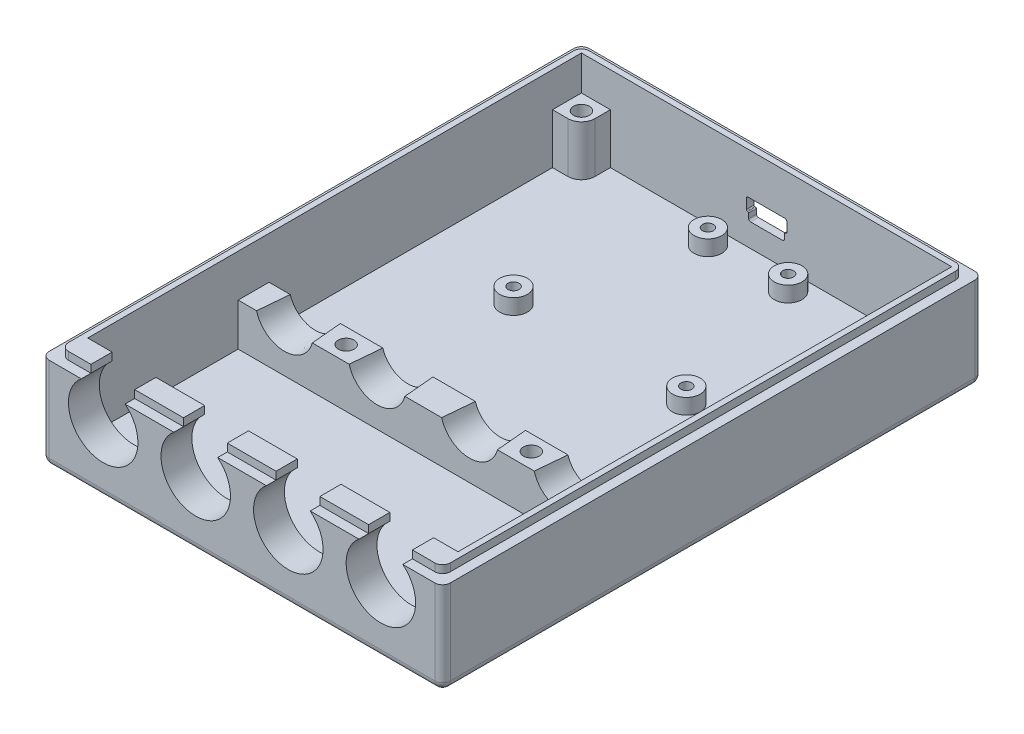
from build123d import *

# Parameters (mm, degrees)
SKETCH1_W                                       = 82.55
SKETCH1_H                                       = 111.125
BOSS_EXTRUDE1_DEPTH                             = 19.05
SKETCH14_W                                      = 76.2
SKETCH14_H                                      = 101.6
CUT_EXTRUDE3_DEPTH                              = 15.875
CUT_EXTRUDE4_REACH                              = 113.125
SKETCH11_R                                      = 7.1501
SKETCH17_W                                      = 76.2
SKETCH17_H                                      = 6.35
BOSS_EXTRUDE4_DEPTH                             = 10.3251
SKETCH18_R                                      = 5.953125
CUT_EXTRUDE5_DEPTH                              = 6.35
CUT_EXTRUDE5_TAPER                              = 5
CUT_EXTRUDE7_REACH                              = 113.125
FILLET6_R                                       = 1.5875
SKETCH19_R                                      = 2.8575
BOSS_EXTRUDE8_DEPTH                             = 3.175
CBORE_FOR_4_PAN_HEAD_MACHINE_SCREW3_D           = 3.2639
CBORE_FOR_4_PAN_HEAD_MACHINE_SCREW3_CBORE_D     = 6.35
CBORE_FOR_4_PAN_HEAD_MACHINE_SCREW3_CBORE_DEPTH = 2.032
F_4_40_TAPPED_HOLE1_D                           = 2.2606
F_4_40_TAPPED_HOLE1_DEPTH                       = 4.7752
F_4_40_TAPPED_HOLE1_TIP                         = 0.679152758
SKETCH39_W                                      = 17.4625
SKETCH39_H                                      = 14.2875
CUT_EXTRUDE8_DEPTH                              = 1.5875
FILLET7_R                                       = 0.79375
FILLET8_R                                       = 0.1984375
FILLET9_R                                       = 0.396875
SKETCH40_W                                      = 10.03389441
SKETCH40_H                                      = 4.365625
BOSS_EXTRUDE9_DEPTH                             = 1.5875
FILLET10_R                                      = 1.5875
SKETCH41_W                                      = 76.2
SKETCH41_H                                      = 6.35
CUT_EXTRUDE9_DEPTH                              = 1.5875


with BuildPart() as part:
    # Sketch1 → Boss-Extrude1 (new body)
    with BuildSketch(Plane(origin=(0, 0, 0), x_dir=(1, 0, 0), z_dir=(0, 1, 0))):
        Rectangle(SKETCH1_W, SKETCH1_H)
    extrude(amount=BOSS_EXTRUDE1_DEPTH)

    # Sketch14 → Cut-Extrude3 (cut)
    with BuildSketch(Plane(origin=(0, 19.05, 0), x_dir=(-1, 0, 0), z_dir=(0, 1, 0))):
        with Locations((0, -1.5875)):
            Rectangle(SKETCH14_W, SKETCH14_H)
    extrude(amount=-CUT_EXTRUDE3_DEPTH, mode=Mode.SUBTRACT)

    # Sketch11 → Cut-Extrude4 (cut, up to next)
    with BuildSketch(Plane.XY.offset(55.5625), mode=Mode.PRIVATE) as cut_extrude4_sk1:
        with Locations((-28.575, 13.5001)):
            Circle(SKETCH11_R)
    cut_extrude4_tool1 = extrude(cut_extrude4_sk1.sketch, amount=-CUT_EXTRUDE4_REACH, mode=Mode.PRIVATE) & part.part
    add(cut_extrude4_tool1.solids().sort_by_distance((-28.575, 13.5001, 55.5625))[0], mode=Mode.SUBTRACT)
    # Sketch11 → Cut-Extrude4 (cut, up to next)
    with BuildSketch(Plane.XY.offset(55.5625), mode=Mode.PRIVATE) as cut_extrude4_sk2:
        with Locations((-9.525, 13.5001)):
            Circle(SKETCH11_R)
    cut_extrude4_tool2 = extrude(cut_extrude4_sk2.sketch, amount=-CUT_EXTRUDE4_REACH, mode=Mode.PRIVATE) & part.part
    add(cut_extrude4_tool2.solids().sort_by_distance((-9.525, 13.5001, 55.5625))[0], mode=Mode.SUBTRACT)
    # Sketch11 → Cut-Extrude4 (cut, up to next)
    with BuildSketch(Plane.XY.offset(55.5625), mode=Mode.PRIVATE) as cut_extrude4_sk3:
        with Locations((9.525, 13.5001)):
            Circle(SKETCH11_R)
    cut_extrude4_tool3 = extrude(cut_extrude4_sk3.sketch, amount=-CUT_EXTRUDE4_REACH, mode=Mode.PRIVATE) & part.part
    add(cut_extrude4_tool3.solids().sort_by_distance((9.525, 13.5001, 55.5625))[0], mode=Mode.SUBTRACT)
    # Sketch11 → Cut-Extrude4 (cut, up to next)
    with BuildSketch(Plane.XY.offset(55.5625), mode=Mode.PRIVATE) as cut_extrude4_sk4:
        with Locations((28.575, 13.5001)):
            Circle(SKETCH11_R)
    cut_extrude4_tool4 = extrude(cut_extrude4_sk4.sketch, amount=-CUT_EXTRUDE4_REACH, mode=Mode.PRIVATE) & part.part
    add(cut_extrude4_tool4.solids().sort_by_distance((28.575, 13.5001, 55.5625))[0], mode=Mode.SUBTRACT)

    # Sketch17 → Boss-Extrude4 (add)
    with BuildSketch(Plane(origin=(0, 3.175, 0), x_dir=(-1, 0, 0), z_dir=(0, 1, 0))):
        with Locations((0, 15.08125)):
            Rectangle(SKETCH17_W, SKETCH17_H)
        with BuildLine():
            Line((32.146875, -49.2125), (32.146875, -52.3875))
            Line((32.146875, -52.3875), (38.1, -52.3875))
            Line((38.1, -52.3875), (38.1, -46.434375))
            Line((38.1, -46.434375), (34.925, -46.434375))
            ThreePointArc((34.925, -46.434375), (32.960568974, -47.248068974), (32.146875, -49.2125))
        make_face()
        with BuildLine():
            Line((-32.146875, -49.2125), (-32.146875, -52.3875))
            Line((-32.146875, -52.3875), (-38.1, -52.3875))
            Line((-38.1, -52.3875), (-38.1, -46.434375))
            Line((-38.1, -46.434375), (-34.925, -46.434375))
            ThreePointArc((-34.925, -46.434375), (-32.960568974, -47.248068974), (-32.146875, -49.2125))
        make_face()
    extrude(amount=BOSS_EXTRUDE4_DEPTH)

    # Sketch18 → Cut-Extrude5 (cut)
    with BuildSketch(Plane.XY.offset(18.25625)):
        with Locations((-28.575, 13.5001)):
            Circle(SKETCH18_R)
        with Locations((-9.525, 13.5001)):
            Circle(SKETCH18_R)
        with Locations((9.525, 13.5001)):
            Circle(SKETCH18_R)
        with Locations((28.575, 13.5001)):
            Circle(SKETCH18_R)
    extrude(amount=-CUT_EXTRUDE5_DEPTH, taper=CUT_EXTRUDE5_TAPER, mode=Mode.SUBTRACT)

    # Sketch21 → Cut-Extrude7 (cut, up to next)
    with BuildSketch(Plane(origin=(0, 0, -55.5625), x_dir=(-1, 0, 0), z_dir=(0, 0, -1)), mode=Mode.PRIVATE) as cut_extrude7_sk1:
        Polygon((-3.683, 7.9375), (-3.683, 9.525), (-4.1671875, 9.525), (-4.1671875, 12.1046875), (4.1671875, 12.1046875), (4.1671875, 9.525), (3.683, 9.525), (3.683, 7.9375), align=None)
    cut_extrude7_tool1 = extrude(cut_extrude7_sk1.sketch, amount=-CUT_EXTRUDE7_REACH, mode=Mode.PRIVATE) & part.part
    add(cut_extrude7_tool1.solids().sort_by_distance((0, 10.08083, -55.5625))[0], mode=Mode.SUBTRACT)

    # Fillet6
    fillet6_edges = [part.edges().sort_by_distance(p)[0] for p in [
        (0, 0, 55.5625),
        (-41.275, 0, 0),
        (0, 0, -55.5625),
        (41.275, 0, 0),
        (41.275, 9.525, 55.5625),
        (-41.275, 9.525, 55.5625),
        (-41.275, 9.525, -55.5625),
        (41.275, 9.525, -55.5625),
    ]]
    fillet(fillet6_edges, radius=FILLET6_R)

    # Sketch19 → Boss-Extrude8 (add)
    with BuildSketch(Plane(origin=(0, 3.175, 0), x_dir=(-1, 0, 0), z_dir=(0, 1, 0))):
        with Locations((8.255, -48.5775)):
            Circle(SKETCH19_R)
        with Locations((-8.255, -48.5775)):
            Circle(SKETCH19_R)
        with Locations((17.78, -18.0975)):
            Circle(SKETCH19_R)
        with Locations((-17.78, -18.0975)):
            Circle(SKETCH19_R)
    extrude(amount=BOSS_EXTRUDE8_DEPTH)

    # CBORE for #4 Pan Head Machine Screw3 (through all)
    with Locations(Plane.XZ):
        with Locations((-19.05, 15.08125), (19.05, 15.08125), (-34.925, -49.2125), (34.925, -49.2125)):
            CounterBoreHole(CBORE_FOR_4_PAN_HEAD_MACHINE_SCREW3_D / 2, CBORE_FOR_4_PAN_HEAD_MACHINE_SCREW3_CBORE_D / 2, CBORE_FOR_4_PAN_HEAD_MACHINE_SCREW3_CBORE_DEPTH)

    # #4-40 Tapped Hole1
    with Locations(Plane(origin=(-31.823802028, 6.35, 11.997353854), x_dir=(-1, 0, 0), z_dir=(0, 1, 0))):
        with Locations((-23.568802028, -60.574853854), (-14.043802028, -30.094853854), (-49.603802028, -30.094853854), (-40.078802028, -60.574853854)):
            Hole(F_4_40_TAPPED_HOLE1_D / 2, depth=F_4_40_TAPPED_HOLE1_DEPTH)
            with Locations((0, 0, -(F_4_40_TAPPED_HOLE1_DEPTH + F_4_40_TAPPED_HOLE1_TIP / 2))):  # 118° drill point
                Cone(0, F_4_40_TAPPED_HOLE1_D / 2, F_4_40_TAPPED_HOLE1_TIP, mode=Mode.SUBTRACT)

    # Sketch39 → Cut-Extrude8 (cut)
    with BuildSketch(Plane(origin=(0, 0, -55.5625), x_dir=(-1, 0, 0), z_dir=(0, 0, -1))):
        with Locations((0, 10.02109375)):
            Rectangle(SKETCH39_W, SKETCH39_H)
    extrude(amount=-CUT_EXTRUDE8_DEPTH, mode=Mode.SUBTRACT)

    # Fillet7
    fillet7_edges = [part.edges().sort_by_distance(p)[0] for p in [
        (-8.73125, 17.16484375, -54.76875),
        (-8.73125, 2.87734375, -54.76875),
        (8.73125, 2.87734375, -54.76875),
        (8.73125, 17.16484375, -54.76875),
    ]]
    fillet(fillet7_edges, radius=FILLET7_R)

    # Fillet8
    fillet8_edges = [part.edges().sort_by_distance(p)[0] for p in [
        (3.683, 9.525, -53.18125),
        (4.1671875, 9.525, -53.18125),
        (-4.1671875, 9.525, -53.18125),
        (-3.683, 9.525, -53.18125),
    ]]
    fillet(fillet8_edges, radius=FILLET8_R)

    # Fillet9
    fillet9_edges = [part.edges().sort_by_distance(p)[0] for p in [
        (-3.683, 7.9375, -53.18125),
        (3.683, 7.9375, -53.18125),
        (4.1671875, 12.1046875, -53.18125),
        (-4.1671875, 12.1046875, -53.18125),
    ]]
    fillet(fillet9_edges, radius=FILLET9_R)

    # Sketch40 → Boss-Extrude9 (add)
    with BuildSketch(Plane(origin=(0, 19.05, 0), x_dir=(1, 0, 0), z_dir=(0, 1, 0))):
        Polygon((-33.083052795, -49.2125), (-33.083052795, -53.578125), (-39.290625, -53.578125), (-39.290625, 53.578125), (39.290625, 53.578125), (39.290625, -53.578125), (33.083052795, -53.578125), (33.083052795, -49.2125), (38.1, -49.2125), (38.1, 52.3875), (-38.1, 52.3875), (-38.1, -49.2125), align=None)
        with Locations((-19.05, -51.3953125)):
            Rectangle(SKETCH40_W, SKETCH40_H)
        with Locations((0, -51.3953125)):
            Rectangle(SKETCH40_W, SKETCH40_H)
        with Locations((19.05, -51.3953125)):
            Rectangle(SKETCH40_W, SKETCH40_H)
    extrude(amount=BOSS_EXTRUDE9_DEPTH)

    # Fillet10
    fillet10_edges = [part.edges().sort_by_distance(p)[0] for p in [
        (-39.290625, 19.84375, -53.578125),
        (-39.290625, 19.84375, 53.578125),
        (39.290625, 19.84375, 53.578125),
        (39.290625, 19.84375, -53.578125),
    ]]
    fillet(fillet10_edges, radius=FILLET10_R)

    # Sketch41 → Cut-Extrude9 (cut)
    with BuildSketch(Plane(origin=(0, 13.5001, 0), x_dir=(1, 0, 0), z_dir=(0, 1, 0))):
        with Locations((0, -15.08125)):
            Rectangle(SKETCH41_W, SKETCH41_H)
    extrude(amount=-CUT_EXTRUDE9_DEPTH, mode=Mode.SUBTRACT)


solid = part.part
